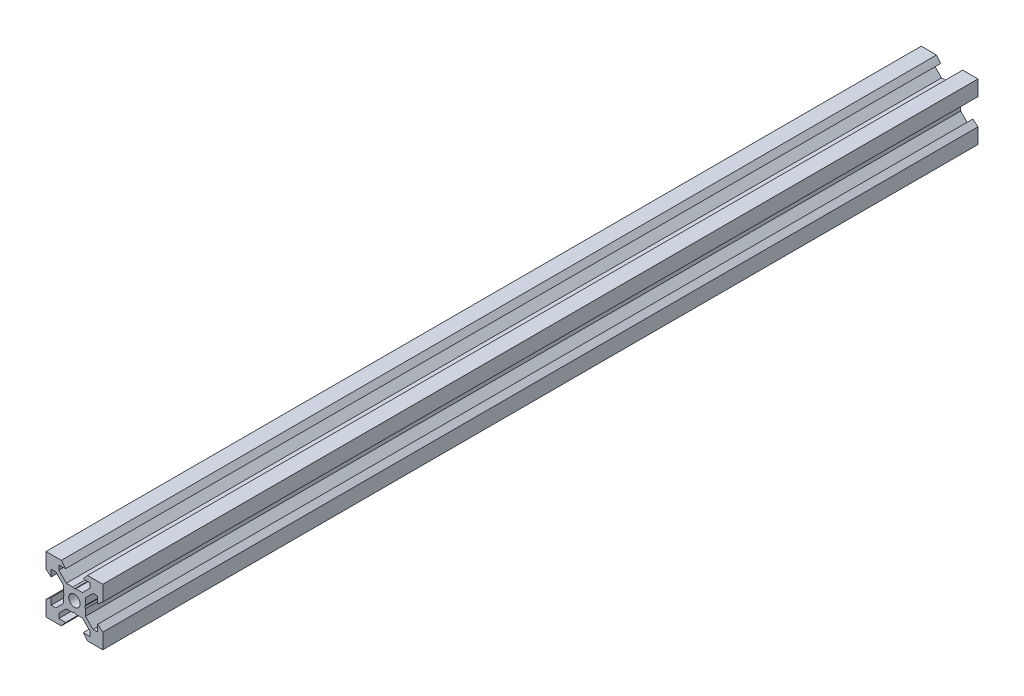
from build123d import *

# Parameters (mm, degrees)
SKETCH1_R           = 2
BOSS_EXTRUDE1_DEPTH = 154.165


with BuildPart() as part:
    # Sketch1 → Boss-Extrude1 (new body, symmetric)
    with BuildSketch(Plane.XY):
        Polygon((10, 10), (10, 4.610379336), (8.2, 3.1), (8.2, 5.5), (6.560660172, 5.5), (3.9, 2.839339828), (3.9, 0.519615242), (3.6, 0), (3.9, -0.519615242), (3.9, -2.839339828), (6.560660172, -5.5), (8.2, -5.5), (8.2, -3.1), (10, -4.610379336), (10, -10), (4.610379336, -10), (3.1, -8.2), (5.5, -8.2), (5.5, -6.560660172), (2.839339828, -3.9), (0.519615242, -3.9), (0, -3.6), (-0.519615242, -3.9), (-2.839339828, -3.9), (-5.5, -6.560660172), (-5.5, -8.2), (-3.1, -8.2), (-4.610379336, -10), (-10, -10), (-10, -4.610379336), (-8.2, -3.1), (-8.2, -5.5), (-6.560660172, -5.5), (-3.9, -2.839339828), (-3.9, -0.519615242), (-3.6, 0), (-3.9, 0.519615242), (-3.9, 2.839339828), (-6.560660172, 5.5), (-8.2, 5.5), (-8.2, 3.1), (-10, 4.610379336), (-10, 10), (-4.610379336, 10), (-3.1, 8.2), (-5.5, 8.2), (-5.5, 6.560660172), (-2.839339828, 3.9), (-0.519615242, 3.9), (0, 3.6), (0.519615242, 3.9), (2.839339828, 3.9), (5.5, 6.560660172), (5.5, 8.2), (3.1, 8.2), (4.610379336, 10), align=None)
        Circle(SKETCH1_R, mode=Mode.SUBTRACT)
    extrude(amount=BOSS_EXTRUDE1_DEPTH, both=True)


solid = part.part
